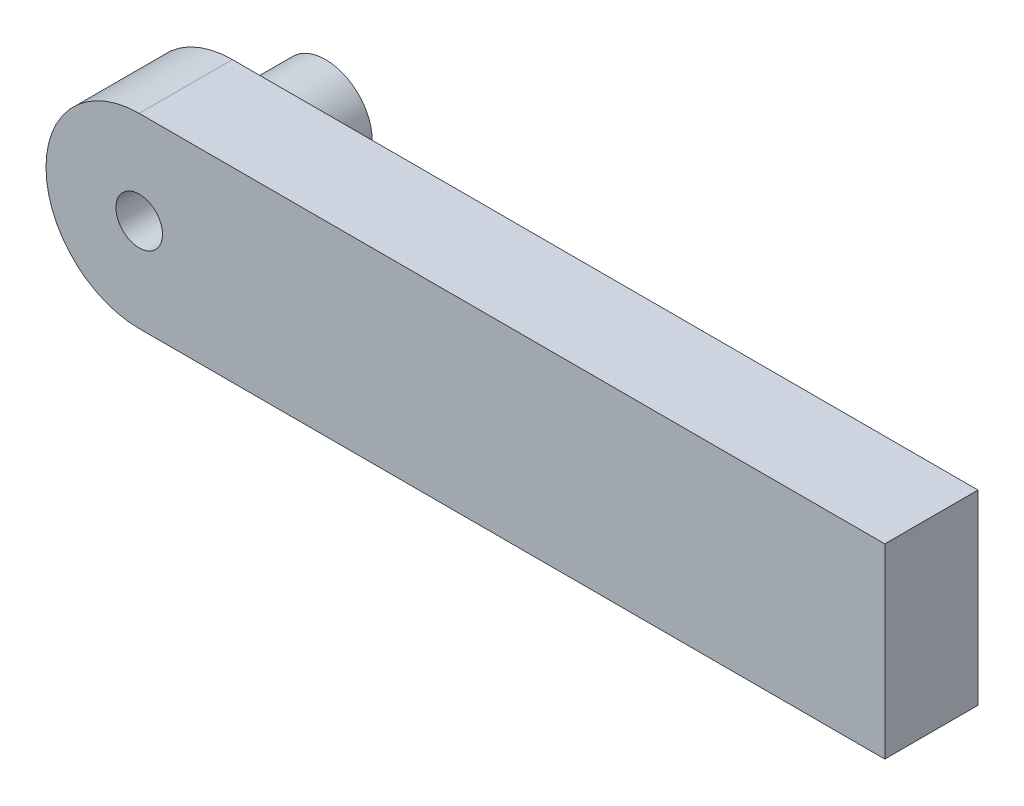
from build123d import *

# Parameters (mm, degrees)
ESTRUSIONE_ESTRUSIONE1_DEPTH = 5
SCHIZZO2_R                   = 2.5
ESTRUSIONE_ESTRUSIONE2_DEPTH = 5
SCHIZZO3_R                   = 1.25
TAGLIO_ESTRUSIONE1_DEPTH     = 28.481102698


with BuildPart() as part:
    # Schizzo1 → Estrusione-Estrusione1 (new body)
    with BuildSketch(Plane.XY):
        with BuildLine():
            Line((20, 4.503546099), (-20, 4.503546099))
            ThreePointArc((-20, 4.503546099), (-25, -0.496453901), (-20, -5.496453901))
            Line((-20, -5.496453901), (20, -5.496453901))
            Line((20, -5.496453901), (20, 4.503546099))
        make_face()
    extrude(amount=ESTRUSIONE_ESTRUSIONE1_DEPTH)

    # Schizzo2 → Estrusione-Estrusione2 (add)
    with BuildSketch(Plane(origin=(0, 0, 0), x_dir=(-1, 0, 0), z_dir=(0, 0, -1))):
        with Locations((20, -0.496453901)):
            Circle(SCHIZZO2_R)
    extrude(amount=ESTRUSIONE_ESTRUSIONE2_DEPTH)

    # Schizzo3 → Taglio-Estrusione1 (cut, through all)
    with BuildSketch(Plane(origin=(0, 0, -5), x_dir=(-1, 0, 0), z_dir=(0, 0, -1))):
        with Locations((20, -0.496453901)):
            Circle(SCHIZZO3_R)
    extrude(amount=-TAGLIO_ESTRUSIONE1_DEPTH, mode=Mode.SUBTRACT)


solid = part.part
